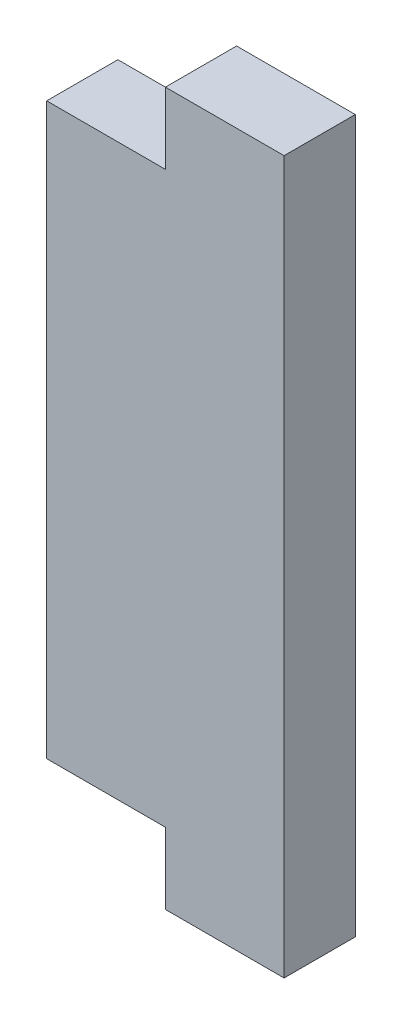
from build123d import *

# Parameters (mm, degrees)
BOSS_EXTRUDE1_DEPTH = 6


with BuildPart() as part:
    # Sketch1 → Boss-Extrude1 (new body)
    with BuildSketch(Plane.XY):
        Polygon((-10, 60), (0, 60), (0, 0), (-10, 0), (-10, 6), (-20, 6), (-20, 54), (-10, 54), align=None)
    extrude(amount=BOSS_EXTRUDE1_DEPTH)


solid = part.part
